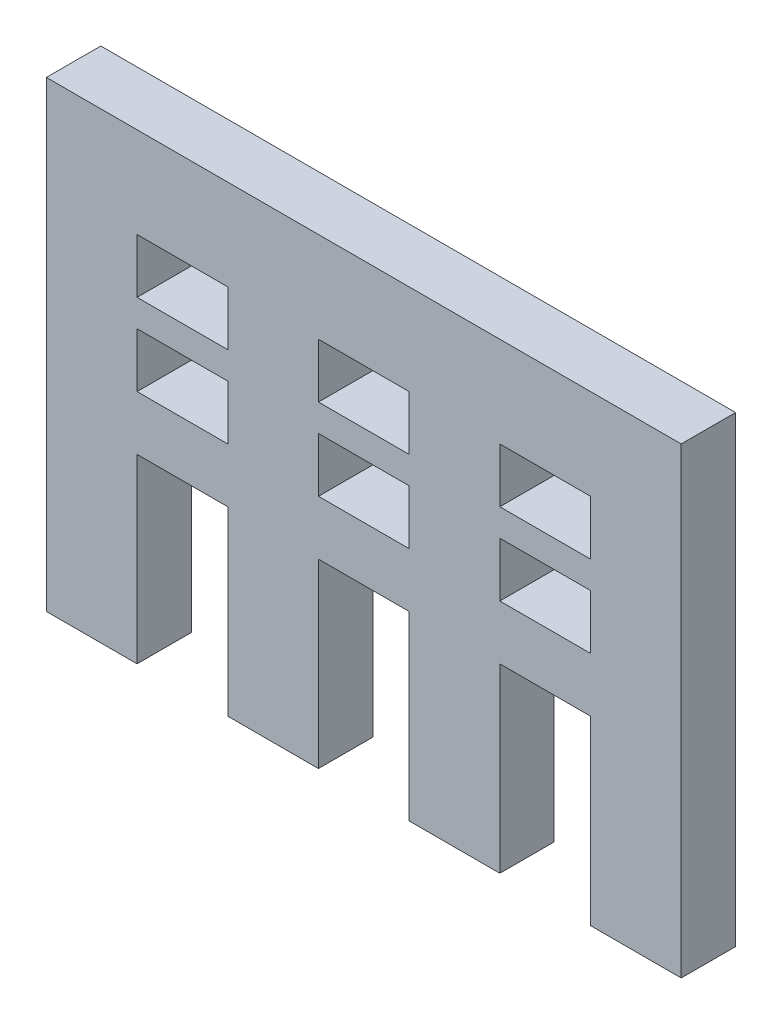
from build123d import *

# Parameters (mm, degrees)
ESQUISSE1_W        = 5
ESQUISSE1_H        = 3
BOSS_EXTRU_1_DEPTH = 3


with BuildPart() as part:
    # Esquisse1 → Boss.-Extru.1 (new body)
    with BuildSketch(Plane.XY):
        Polygon((-20, -10), (-20, 0), (-15, 0), (-15, -10), (-10, -10), (-10, 0), (-5, 0), (-5, -10), (0, -10), (0, 15.5), (-35, 15.5), (-35, -10), (-30, -10), (-30, 0), (-25, 0), (-25, -10), align=None)
        with Locations((-7.5, 9)):
            Rectangle(ESQUISSE1_W, ESQUISSE1_H, mode=Mode.SUBTRACT)
        with Locations((-17.5, 9)):
            Rectangle(ESQUISSE1_W, ESQUISSE1_H, mode=Mode.SUBTRACT)
        with Locations((-27.5, 9)):
            Rectangle(ESQUISSE1_W, ESQUISSE1_H, mode=Mode.SUBTRACT)
        with Locations((-7.5, 4.5)):
            Rectangle(ESQUISSE1_W, ESQUISSE1_H, mode=Mode.SUBTRACT)
        with Locations((-17.5, 4.5)):
            Rectangle(ESQUISSE1_W, ESQUISSE1_H, mode=Mode.SUBTRACT)
        with Locations((-27.5, 4.5)):
            Rectangle(ESQUISSE1_W, ESQUISSE1_H, mode=Mode.SUBTRACT)
    extrude(amount=BOSS_EXTRU_1_DEPTH)


solid = part.part
